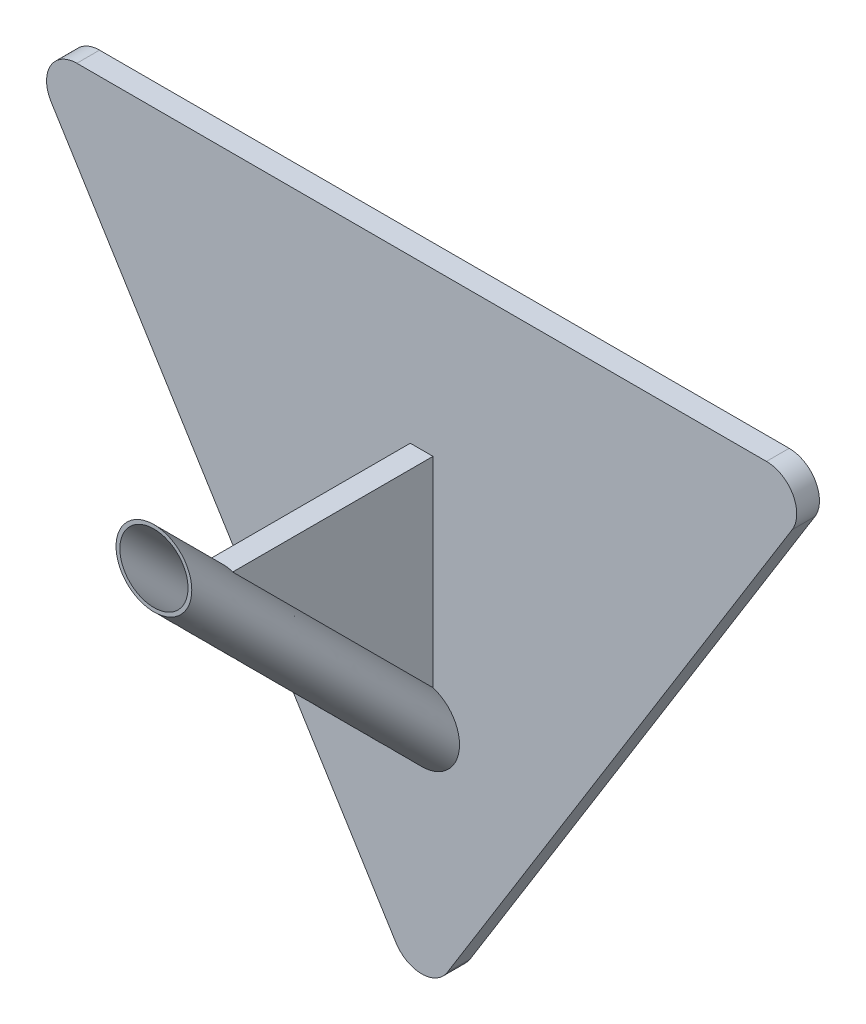
from build123d import *

# Parameters (mm, degrees)
BOSS_EXTRU_1_DEPTH = 3
ESQUISSE5_R        = 5
ESQUISSE7_R        = 4.5
NERVURE4_REACH     = 109.103
ESQUISSE10_WALL_W  = 242.432835572
ESQUISSE10_WALL_H  = 3
CONG_1_R           = 4


with BuildPart() as part:
    # Esquisse1 → Boss.-Extru.1 (new body)
    with BuildSketch(Plane.XY):
        Polygon((0, 0), (-52.726441393, 84.970126386), (52.726441393, 84.970126386), align=None)
    extrude(amount=BOSS_EXTRU_1_DEPTH)

    # Balayage1: sweep along a path in Esquisse6
    with BuildLine(Plane(origin=(0, 0, 0), x_dir=(0, 0, -1), z_dir=(1, 0, 0))) as balayage1_path:
        Line((-3, 32.30290769), (-38.355339059, 67.65824675))
    # Esquisse5 → Balayage1 (sweep)
    with BuildSketch(Plane.XY.offset(3)):
        with Locations((0, 32.30290769)):
            Circle(ESQUISSE5_R)
    sweep(path=balayage1_path.line)

    # Enlèvement de matière-Balayage1: sweep along a path in Esquisse6_2
    with BuildLine(Plane(origin=(0, 0, 0), x_dir=(0, 0, -1), z_dir=(1, 0, 0))) as enl_vement_de_mati_re_balayage1_path:
        Line((-3, 32.30290769), (-38.355339059, 67.65824675))
    # Esquisse7 → Enlèvement de matière-Balayage1 (sweep, cut)
    with BuildSketch(Plane.XY.offset(3)):
        with Locations((0, 32.30290769)):
            Circle(ESQUISSE7_R)
    sweep(path=enl_vement_de_mati_re_balayage1_path.line, mode=Mode.SUBTRACT)

    # Esquisse10 wall → Nervure4 (add, up to next)
    with BuildSketch(Plane(origin=(0, 63.529001685, 16.113046997), x_dir=(0, 0, -1), z_dir=(0, 1, 0)), mode=Mode.PRIVATE) as nervure4_sk1:
        Rectangle(ESQUISSE10_WALL_W, ESQUISSE10_WALL_H)
    nervure4_tool1 = extrude(nervure4_sk1.sketch, amount=-NERVURE4_REACH, mode=Mode.PRIVATE) - part.part
    add(nervure4_tool1.solids().sort_by_distance((0, 63.529001685, 16.113046997))[0])

    # Congé1
    cong_1_edges = [part.edges().sort_by_distance(p)[0] for p in [
        (0, 0, 1.5),
        (-52.726441393, 84.970126386, 1.5),
        (52.726441393, 84.970126386, 1.5),
    ]]
    fillet(cong_1_edges, radius=CONG_1_R)


solid = part.part
